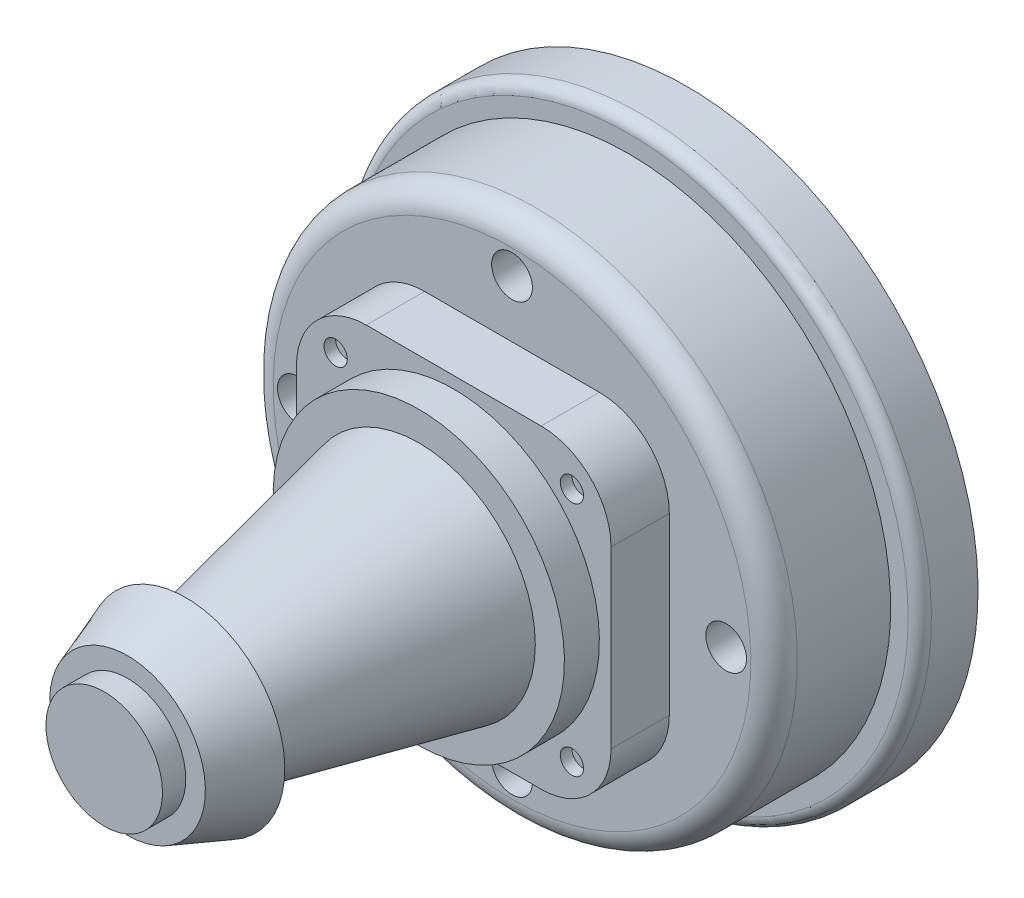
from build123d import *

# Parameters (mm, degrees)
SKETCH1_R             = 25
BOSS_EXTRUDE1_DEPTH   = 5
SKETCH2_R             = 22.5
BOSS_EXTRUDE2_DEPTH   = 10
SKETCH3_W             = 27
SKETCH3_H             = 27
BOSS_EXTRUDE3_DEPTH   = 5
SKETCH5_R             = 12.5
BOSS_EXTRUDE4_DEPTH   = 3
SKETCH6_R             = 10
BOSS_EXTRUDE5_DEPTH   = 20
BOSS_EXTRUDE5_TAPER   = 12
SKETCH7_R             = 8.5
BOSS_EXTRUDE6_DEPTH   = 5
BOSS_EXTRUDE6_TAPER   = 20
SKETCH8_R             = 5
BOSS_EXTRUDE7_DEPTH   = 2
FILLET1_R             = 6
SKETCH10_R            = 1.75
CUT_EXTRUDE2_DEPTH    = 5
SKETCH11_R            = 1
CUT_EXTRUDE3_DEPTH    = 1
SKETCH12_R            = 10
CUT_EXTRUDE4_DEPTH    = 5
FILLET2_R             = 2
FILLET3_R             = 1
BODY_MOVE_COPY2_ANGLE = 90


with BuildPart() as part:
    # Sketch1 → Boss-Extrude1 (new body)
    with BuildSketch(Plane(origin=(0, 0, 0), x_dir=(1, 0, 0), z_dir=(0, 1, 0))):
        Circle(SKETCH1_R)
    extrude(amount=BOSS_EXTRUDE1_DEPTH)

    # Sketch2 → Boss-Extrude2 (add)
    with BuildSketch(Plane(origin=(0, 5, 0), x_dir=(1, 0, 0), z_dir=(0, 1, 0))):
        Circle(SKETCH2_R)
    extrude(amount=BOSS_EXTRUDE2_DEPTH)

    # Sketch3 → Boss-Extrude3 (add)
    with BuildSketch(Plane(origin=(0, 15, 0), x_dir=(1, 0, 0), z_dir=(0, 1, 0))):
        Rectangle(SKETCH3_W, SKETCH3_H)
    extrude(amount=BOSS_EXTRUDE3_DEPTH)

    # Sketch5 → Boss-Extrude4 (add)
    with BuildSketch(Plane(origin=(0, 20, 0), x_dir=(1, 0, 0), z_dir=(0, 1, 0))):
        Circle(SKETCH5_R)
    extrude(amount=BOSS_EXTRUDE4_DEPTH)

    # Sketch6 → Boss-Extrude5 (add)
    with BuildSketch(Plane(origin=(0, 23, 0), x_dir=(1, 0, 0), z_dir=(0, 1, 0))):
        Circle(SKETCH6_R)
    extrude(amount=BOSS_EXTRUDE5_DEPTH, taper=BOSS_EXTRUDE5_TAPER)

    # Sketch7 → Boss-Extrude6 (add)
    with BuildSketch(Plane(origin=(0, 43, 0), x_dir=(1, 0, 0), z_dir=(0, 1, 0))):
        Circle(SKETCH7_R)
    extrude(amount=BOSS_EXTRUDE6_DEPTH, taper=BOSS_EXTRUDE6_TAPER)

    # Sketch8 → Boss-Extrude7 (add)
    with BuildSketch(Plane(origin=(0, 48, 0), x_dir=(1, 0, 0), z_dir=(0, 1, 0))):
        Circle(SKETCH8_R)
    extrude(amount=BOSS_EXTRUDE7_DEPTH)

    # Fillet1
    fillet1_edges = [part.edges().sort_by_distance(p)[0] for p in [
        (13.5, 17.5, 13.5),
        (13.5, 17.5, -13.5),
        (-13.5, 17.5, -13.5),
        (-13.5, 17.5, 13.5),
    ]]
    fillet(fillet1_edges, radius=FILLET1_R)

    # Sketch10 → Cut-Extrude2 (cut)
    with BuildSketch(Plane(origin=(0, 15, 0), x_dir=(1, 0, 0), z_dir=(0, 1, 0))):
        with Locations((-18.379384185, 0)):
            Circle(SKETCH10_R)
        with Locations((0, 18.400220003)):
            Circle(SKETCH10_R)
    cut_extrude2 = extrude(amount=-CUT_EXTRUDE2_DEPTH, mode=Mode.SUBTRACT)

    # Sketch11 → Cut-Extrude3 (cut)
    with BuildSketch(Plane(origin=(0, 20, 0), x_dir=(1, 0, 0), z_dir=(0, 1, 0))):
        with Locations((10.139251665, 10.139251665)):
            Circle(SKETCH11_R)
        with Locations((-10.139251665, 10.139251665)):
            Circle(SKETCH11_R)
    cut_extrude3 = extrude(amount=-CUT_EXTRUDE3_DEPTH, mode=Mode.SUBTRACT)

    # Mirror4: Cut-Extrude2, Cut-Extrude3 across plane
    add(cut_extrude2.mirror(Plane.XY), mode=Mode.SUBTRACT)
    add(cut_extrude3.mirror(Plane.XY), mode=Mode.SUBTRACT)

    # Mirror6: Cut-Extrude2 across plane
    add(cut_extrude2.mirror(Plane(origin=(0, 0, 0), x_dir=(0, 0, 1), z_dir=(1, 0, 0))), mode=Mode.SUBTRACT)

    # Sketch12 → Cut-Extrude4 (cut)
    with BuildSketch(Plane.XZ):
        Circle(SKETCH12_R)
    extrude(amount=-CUT_EXTRUDE4_DEPTH, mode=Mode.SUBTRACT)

    # Fillet2
    fillet2_edges = [part.edges().sort_by_distance(p)[0] for p in [
        (-22.5, 15, 0),
    ]]
    fillet(fillet2_edges, radius=FILLET2_R)

    # Fillet3
    fillet3_edges = [part.edges().sort_by_distance(p)[0] for p in [
        (-25, 5, 0),
    ]]
    fillet(fillet3_edges, radius=FILLET3_R)


with BuildPart() as part_1:
    # Body-Move/Copy1: moved
    add(part.part.moved(Location((0, -5, 0))))


with BuildPart() as part_2:
    # Body-Move/Copy2: moved
    add(part_1.part.rotate(Axis((0, 0, 0), (1, 0, 0)), BODY_MOVE_COPY2_ANGLE))


solid = part_2.part
